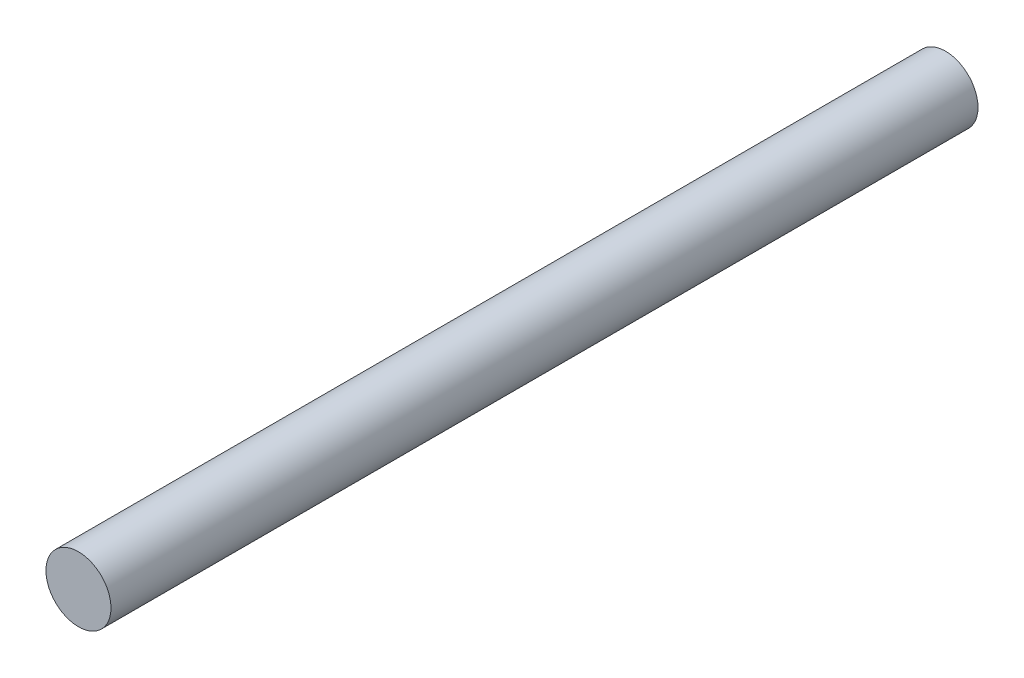
from build123d import *

# Parameters (mm, degrees)
SKETCH_1_R      = 4.5
EXTRUDE_1_DEPTH = 120


with BuildPart() as part:
    # Эскиз1 → Бобышка-Вытянуть1 (new body)
    with BuildSketch(Plane.XY):
        Circle(SKETCH_1_R)
    extrude(amount=EXTRUDE_1_DEPTH)


solid = part.part
